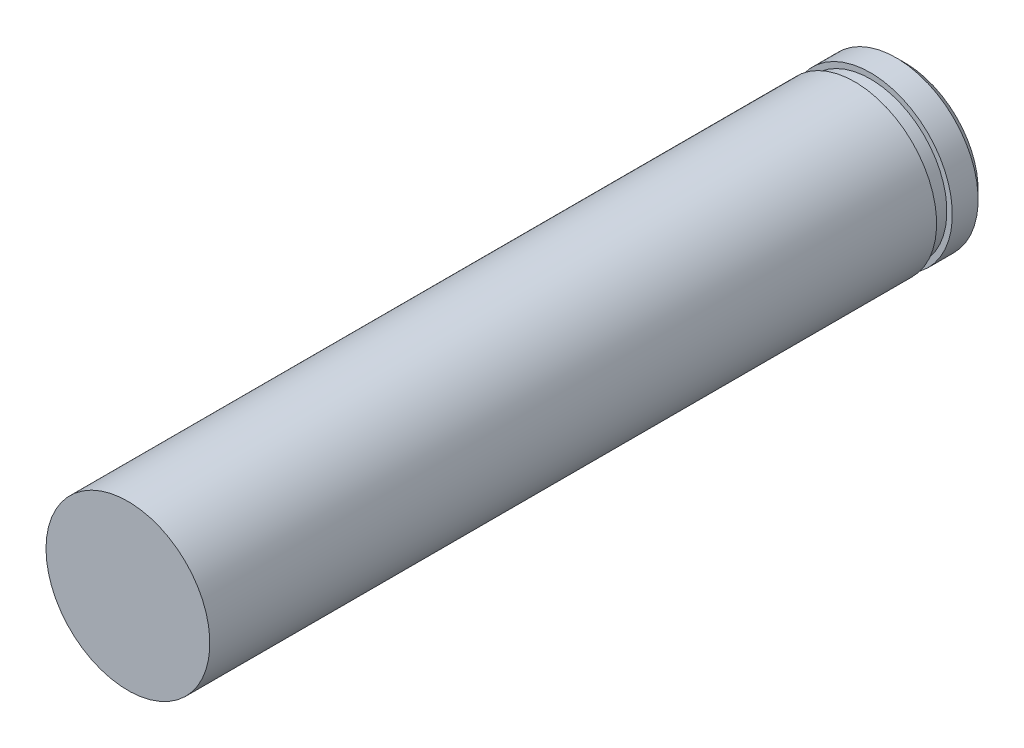
from build123d import *

# Parameters (mm, degrees)
CHAMFER1_SIZE = 0.25


with BuildPart() as part:
    # Sketch1 → Revolve1 (revolve)
    with BuildSketch(Plane(origin=(0, 0, 0), x_dir=(0, 0, -1), z_dir=(1, 0, 0))):
        Polygon((0, 0), (22.58116, 0), (22.58116, 2.38125), (21.58116, 2.38125), (21.58116, 2.2225), (21.12396, 2.2225), (21.12396, 2.38125), (0, 2.38125), align=None)
    revolve(axis=Axis((0, 0, 0), (0, 0, 1)))

    # Chamfer1
    chamfer1_edges = [part.edges().sort_by_distance(p)[0] for p in [
        (0, -2.38125, -22.58116),
    ]]
    chamfer(chamfer1_edges, length=CHAMFER1_SIZE)


solid = part.part
